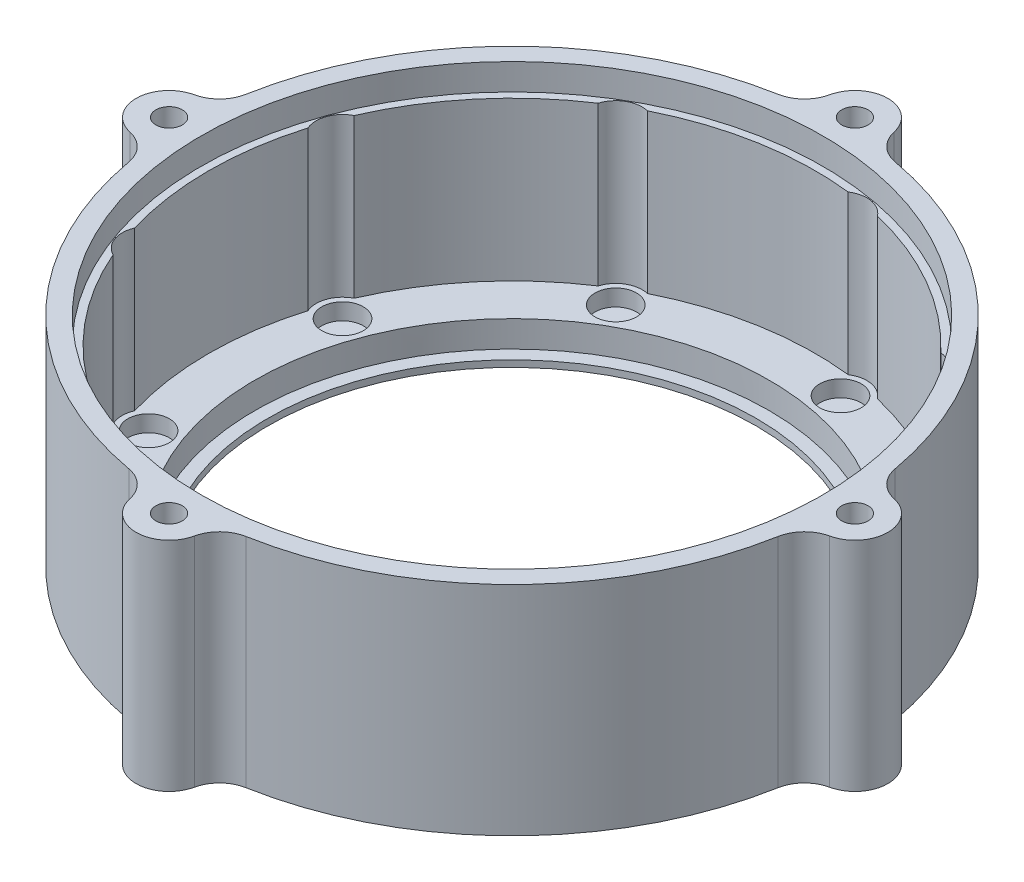
from build123d import *

# Parameters (mm, degrees)
SKETCH1_R           = 50
BOSS_EXTRUDE1_DEPTH = 5
SKETCH2_R           = 3
BOSS_EXTRUDE2_DEPTH = 30
SKETCH3_R           = 50
BOSS_EXTRUDE3_DEPTH = 28
SKETCH4_R           = 39
CUT_EXTRUDE1_DEPTH  = 6
SKETCH5_R           = 3
CUT_EXTRUDE2_DEPTH  = 44
SKETCH6_R           = 50
SKETCH6_R_2         = 39
BOSS_EXTRUDE4_DEPTH = 3
SKETCH7_R           = 47
SKETCH7_R_2         = 46
CUT_EXTRUDE3_DEPTH  = 4
SKETCH8_R           = 39
SKETCH8_R_2         = 37
BOSS_EXTRUDE5_DEPTH = 1
SKETCH9_R           = 5
SKETCH9_R_2         = 2
BOSS_EXTRUDE6_DEPTH = 33
FILLET1_R           = 5
SKETCH10_R          = 3.15
CUT_EXTRUDE6_DEPTH  = 2.5
SKETCH11_R          = 47.15
CUT_EXTRUDE7_DEPTH  = 4


with BuildPart() as part:
    # Sketch1 → Boss-Extrude1 (new body)
    with BuildSketch(Plane(origin=(0, 0, 0), x_dir=(1, 0, 0), z_dir=(0, 1, 0))):
        Circle(SKETCH1_R)
    extrude(amount=BOSS_EXTRUDE1_DEPTH)

    # Sketch2 → Boss-Extrude2 (add)
    with BuildSketch(Plane(origin=(0, 5, 0), x_dir=(1, 0, 0), z_dir=(0, 1, 0))):
        with Locations((43, 0)):
            Circle(SKETCH2_R)
        with Locations((32.939911054, -27.639867217)):
            Circle(SKETCH2_R)
        with Locations((7.46687164, -42.34673338)):
            Circle(SKETCH2_R)
        with Locations((-21.5, -37.239092363)):
            Circle(SKETCH2_R)
        with Locations((-40.406782694, -14.706866163)):
            Circle(SKETCH2_R)
        with Locations((-40.406782694, 14.706866163)):
            Circle(SKETCH2_R)
        with Locations((-21.5, 37.239092363)):
            Circle(SKETCH2_R)
        with Locations((7.46687164, 42.34673338)):
            Circle(SKETCH2_R)
        with Locations((32.939911054, 27.639867217)):
            Circle(SKETCH2_R)
    extrude(amount=BOSS_EXTRUDE2_DEPTH)

    # Sketch3 → Boss-Extrude3 (add)
    with BuildSketch(Plane(origin=(0, 5, 0), x_dir=(1, 0, 0), z_dir=(0, 1, 0))):
        Circle(SKETCH3_R)
        with BuildLine():
            ThreePointArc((45.918604651, 2.735278211), (43.225860556, 15.732926593), (36.933894872, 27.42056545))
            ThreePointArc((36.933894872, 27.42056545), (36.004088827, 30.211017655), (33.417488986, 31.611254798))
            ThreePointArc((33.417488986, 31.611254798), (23, 39.837168574), (10.667405207, 44.746021791))
            ThreePointArc((10.667405207, 44.746021791), (8.16146435, 46.285964392), (5.27995883, 45.695973945))
            ThreePointArc((5.27995883, 45.695973945), (-7.987816173, 45.301156639), (-20.590481909, 41.13431724))
            ThreePointArc((-20.590481909, 41.13431724), (-23.5, 40.703193978), (-25.328122743, 38.399039029))
            ThreePointArc((-25.328122743, 38.399039029), (-35.238044383, 29.568230046), (-42.213853702, 18.275408495))
            ThreePointArc((-42.213853702, 18.275408495), (-44.165553177, 16.074946736), (-44.084894193, 13.134766994))
            ThreePointArc((-44.084894193, 13.134766994), (-46, 0), (-44.084894193, -13.134766994))
            ThreePointArc((-44.084894193, -13.134766994), (-44.165553177, -16.074946736), (-42.213853702, -18.275408495))
            ThreePointArc((-42.213853702, -18.275408495), (-35.238044383, -29.568230046), (-25.328122743, -38.399039029))
            ThreePointArc((-25.328122743, -38.399039029), (-23.5, -40.703193978), (-20.590481909, -41.13431724))
            ThreePointArc((-20.590481909, -41.13431724), (-7.987816173, -45.301156639), (5.27995883, -45.695973945))
            ThreePointArc((5.27995883, -45.695973945), (8.16146435, -46.285964392), (10.667405207, -44.746021791))
            ThreePointArc((10.667405207, -44.746021791), (23, -39.837168574), (33.417488986, -31.611254798))
            ThreePointArc((33.417488986, -31.611254798), (36.004088827, -30.211017655), (36.933894872, -27.42056545))
            ThreePointArc((36.933894872, -27.42056545), (43.225860556, -15.732926593), (45.918604651, -2.735278211))
            ThreePointArc((45.918604651, -2.735278211), (47, 0), (45.918604651, 2.735278211))
        make_face(mode=Mode.SUBTRACT)
    extrude(amount=BOSS_EXTRUDE3_DEPTH)

    # Sketch4 → Cut-Extrude1 (cut)
    with BuildSketch(Plane(origin=(0, 5, 0), x_dir=(1, 0, 0), z_dir=(0, 1, 0))):
        Circle(SKETCH4_R)
    extrude(amount=-CUT_EXTRUDE1_DEPTH, mode=Mode.SUBTRACT)

    # Sketch5 → Cut-Extrude2 (cut, symmetric)
    with BuildSketch(Plane(origin=(0, 5, 0), x_dir=(1, 0, 0), z_dir=(0, 1, 0))):
        with Locations((43, 0)):
            Circle(SKETCH5_R)
        with Locations((32.939911054, -27.639867217)):
            Circle(SKETCH5_R)
        with Locations((7.46687164, -42.34673338)):
            Circle(SKETCH5_R)
        with Locations((-21.5, -37.239092363)):
            Circle(SKETCH5_R)
        with Locations((-40.406782694, -14.706866163)):
            Circle(SKETCH5_R)
        with Locations((-40.406782694, 14.706866163)):
            Circle(SKETCH5_R)
        with Locations((-21.5, 37.239092363)):
            Circle(SKETCH5_R)
        with Locations((7.46687164, 42.34673338)):
            Circle(SKETCH5_R)
        with Locations((32.939911054, 27.639867217)):
            Circle(SKETCH5_R)
    extrude(amount=CUT_EXTRUDE2_DEPTH, both=True, mode=Mode.SUBTRACT)

    # Sketch6 → Boss-Extrude4 (add)
    with BuildSketch(Plane.XZ):
        Circle(SKETCH6_R)
        Circle(SKETCH6_R_2, mode=Mode.SUBTRACT)
    extrude(amount=-BOSS_EXTRUDE4_DEPTH)

    # Sketch7 → Cut-Extrude3 (cut)
    with BuildSketch(Plane(origin=(0, 33, 0), x_dir=(1, 0, 0), z_dir=(0, 1, 0))):
        Circle(SKETCH7_R)
        Circle(SKETCH7_R_2, mode=Mode.SUBTRACT)
    extrude(amount=-CUT_EXTRUDE3_DEPTH, mode=Mode.SUBTRACT)

    # Sketch8 → Boss-Extrude5 (add)
    with BuildSketch(Plane.XZ):
        Circle(SKETCH8_R)
        Circle(SKETCH8_R_2, mode=Mode.SUBTRACT)
    extrude(amount=-BOSS_EXTRUDE5_DEPTH)

    # Sketch9 → Boss-Extrude6 (add)
    with BuildSketch(Plane(origin=(0, 33, 0), x_dir=(1, 0, 0), z_dir=(0, 1, 0))):
        with Locations((52, 0)):
            Circle(SKETCH9_R)
        with Locations((52, 0)):
            Circle(SKETCH9_R_2, mode=Mode.SUBTRACT)
        with Locations((-52, 0)):
            Circle(SKETCH9_R)
        with Locations((-52, 0)):
            Circle(SKETCH9_R_2, mode=Mode.SUBTRACT)
        with Locations((0, 52)):
            Circle(SKETCH9_R)
        with Locations((0, 52)):
            Circle(SKETCH9_R_2, mode=Mode.SUBTRACT)
        with Locations((0, -52)):
            Circle(SKETCH9_R)
        with Locations((0, -52)):
            Circle(SKETCH9_R_2, mode=Mode.SUBTRACT)
    extrude(amount=-BOSS_EXTRUDE6_DEPTH)

    # Fillet1
    fillet1_edges = [part.edges().sort_by_distance(p)[0] for p in [
        (49.798076923, 16.5, 4.489046086),
        (49.798076923, 16.5, -4.489046086),
        (-49.798076923, 16.5, -4.489046086),
        (-49.798076923, 16.5, 4.489046086),
        (4.489046086, 16.5, -49.798076923),
        (-4.489046086, 16.5, -49.798076923),
        (-4.489046086, 16.5, 49.798076923),
        (4.489046086, 16.5, 49.798076923),
    ]]
    fillet(fillet1_edges, radius=FILLET1_R)

    # Sketch10 → Cut-Extrude6 (cut)
    with BuildSketch(Plane(origin=(0, 5, 0), x_dir=(1, 0, 0), z_dir=(0, 1, 0))):
        with Locations((32.939911054, -27.639867217)):
            Circle(SKETCH10_R)
        with Locations((43, 0)):
            Circle(SKETCH10_R)
        with Locations((7.46687164, -42.34673338)):
            Circle(SKETCH10_R)
        with Locations((-21.5, -37.239092363)):
            Circle(SKETCH10_R)
        with Locations((-40.406782694, -14.706866163)):
            Circle(SKETCH10_R)
        with Locations((-40.406782694, 14.706866163)):
            Circle(SKETCH10_R)
        with Locations((-21.5, 37.239092363)):
            Circle(SKETCH10_R)
        with Locations((7.46687164, 42.34673338)):
            Circle(SKETCH10_R)
        with Locations((32.939911054, 27.639867217)):
            Circle(SKETCH10_R)
    extrude(amount=-CUT_EXTRUDE6_DEPTH, mode=Mode.SUBTRACT)

    # Sketch11 → Cut-Extrude7 (cut)
    with BuildSketch(Plane(origin=(0, 33, 0), x_dir=(1, 0, 0), z_dir=(0, 1, 0))):
        Circle(SKETCH11_R)
    extrude(amount=-CUT_EXTRUDE7_DEPTH, mode=Mode.SUBTRACT)


solid = part.part
